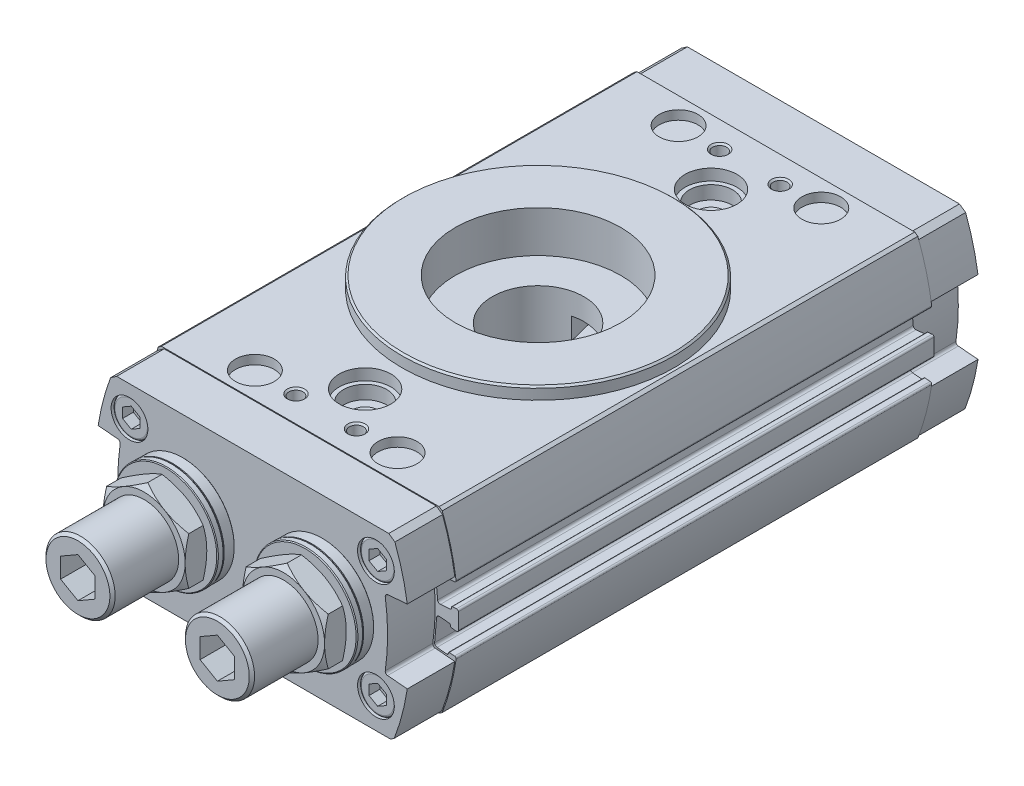
from build123d import *

# Parameters (mm, degrees)
BOSS_EXTRUDE1_DEPTH      = 55
BOSS_EXTRUDE1_DEPTH_BACK = 55
CUT_EXTRUDE1_DEPTH       = 55
CUT_EXTRUDE1_DEPTH_BACK  = 55
CUT_EXTRUDE2_DEPTH       = 55
CUT_EXTRUDE2_DEPTH_BACK  = 55
BOSS_EXTRUDE2_DEPTH      = 11
BOSS_EXTRUDE3_START      = 11
BOSS_EXTRUDE3_DEPTH      = 11
SKETCH16_W               = 4.5
SKETCH16_H               = 2.1
SKETCH17_W               = 4.5
SKETCH17_H               = 2.1
SKETCH18_W               = 4.5
SKETCH18_H               = 2.1
SKETCH19_W               = 4.5
SKETCH19_H               = 2.1
CUT_EXTRUDE3_DEPTH       = 2.5
CUT_EXTRUDE4_DEPTH       = 2.5
CUT_EXTRUDE5_DEPTH       = 2.5
CUT_EXTRUDE6_DEPTH       = 2.5
CUT_EXTRUDE7_DEPTH       = 2.5
CUT_EXTRUDE8_DEPTH       = 2.5
CUT_EXTRUDE9_DEPTH       = 2.5
CUT_EXTRUDE10_DEPTH      = 2.5
BOSS_EXTRUDE4_DEPTH      = 5
BOSS_EXTRUDE5_DEPTH      = 5
CUT_EXTRUDE11_DEPTH      = 6
CUT_EXTRUDE12_DEPTH      = 6
CUT_EXTRUDE13_DEPTH      = 2
CUT_EXTRUDE14_DEPTH      = 2
SKETCH52_W               = 17.125
SKETCH52_H               = 5
CUT_REVOLVE26_ANGLE      = 208


with BuildPart() as part:
    # Sketch1 → Boss-Extrude1 (new, two sides: drawn at the far end of the back side and taken through both)
    with BuildSketch(Plane.XY.offset(-BOSS_EXTRUDE1_DEPTH_BACK)):
        with BuildLine():
            Line((-32.829876508, 0.5), (-32.115802504, 0))
            Line((-32.115802504, 0), (32.115802504, 0))
            Line((32.115802504, 0), (32.829876508, 0.5))
            ThreePointArc((32.829876508, 0.5), (36.6, 20.7), (32.829876508, 40.9))
            Line((32.829876508, 40.9), (32.115802504, 41.4))
            Line((32.115802504, 41.4), (-32.115802504, 41.4))
            Line((-32.115802504, 41.4), (-32.829876508, 40.9))
            ThreePointArc((-32.829876508, 40.9), (-36.6, 20.7), (-32.829876508, 0.5))
        make_face()
    extrude(amount=BOSS_EXTRUDE1_DEPTH + BOSS_EXTRUDE1_DEPTH_BACK)

    # Sketch2 → Cut-Extrude1 (cut, two sides: drawn at the far end of the back side and taken through both)
    with BuildSketch(Plane.XY.offset(-CUT_EXTRUDE1_DEPTH_BACK)):
        with BuildLine():
            Line((31.617877692, 12.954236438), (33.909125497, 12.753778229))
            ThreePointArc((33.909125497, 12.753778229), (34.128108503, 12.822823306), (34.23413063, 13.026489916))
            Line((34.23413063, 13.026489916), (34.247203991, 13.175919121))
            ThreePointArc((34.247203991, 13.175919121), (34.317885409, 13.311696861), (34.463874079, 13.357726912))
            Line((34.463874079, 13.357726912), (35.678340958, 13.251474828))
            ThreePointArc((35.678340958, 13.251474828), (35.956768235, 13.101692833), (36.03947491, 12.796543689))
            Line((36.03947491, 12.796543689), (41.6, 12.796543689))
            Line((41.6, 12.796543689), (41.6, 28.583696395))
            Line((41.6, 28.583696395), (36.042288293, 28.583696395))
            ThreePointArc((36.042288293, 28.583696395), (35.959517197, 28.278632566), (35.681134245, 28.128906398))
            Line((35.681134245, 28.128906398), (34.690910982, 28.042273088))
            ThreePointArc((34.690910982, 28.042273088), (34.544922312, 28.088303139), (34.474240894, 28.224080879))
            Line((34.474240894, 28.224080879), (34.461167533, 28.373510084))
            ThreePointArc((34.461167533, 28.373510084), (34.355145406, 28.577176694), (34.1361624, 28.646221771))
            Line((34.1361624, 28.646221771), (31.844914595, 28.445763562))
            ThreePointArc((31.844914595, 28.445763562), (31.437581375, 28.233719309), (31.299491222, 27.795753298))
            Line((31.299491222, 27.795753298), (31.761416658, 22.515921398))
            ThreePointArc((31.761416658, 22.515921398), (31.973460911, 22.108588178), (32.411426923, 21.970498025))
            Line((32.411426923, 21.970498025), (34.702674728, 22.170956233))
            ThreePointArc((34.702674728, 22.170956233), (34.906341338, 22.27697836), (34.975386415, 22.495961365))
            Line((34.975386415, 22.495961365), (34.962313054, 22.64539057))
            ThreePointArc((34.962313054, 22.64539057), (35.008343105, 22.791379241), (35.144120845, 22.862060658))
            Line((35.144120845, 22.862060658), (36.134344107, 22.948693968))
            ThreePointArc((36.134344107, 22.948693968), (36.434497473, 22.849583169), (36.568984868, 22.563526996))
            ThreePointArc((36.568984868, 22.563526996), (36.599999111, 20.690020595), (36.568317138, 18.816525367))
            ThreePointArc((36.568317138, 18.816525367), (36.433781161, 18.530564406), (36.133681147, 18.431500878))
            Line((36.133681147, 18.431500878), (34.917083941, 18.537939342))
            ThreePointArc((34.917083941, 18.537939342), (34.781306201, 18.608620759), (34.73527615, 18.75460943))
            Line((34.73527615, 18.75460943), (34.748349512, 18.904038635))
            ThreePointArc((34.748349512, 18.904038635), (34.679304435, 19.12302164), (34.475637825, 19.229043767))
            Line((34.475637825, 19.229043767), (32.18439002, 19.429501975))
            ThreePointArc((32.18439002, 19.429501975), (31.746424008, 19.291411822), (31.534379755, 18.884078602))
            Line((31.534379755, 18.884078602), (31.072454319, 13.604246702))
            ThreePointArc((31.072454319, 13.604246702), (31.210544472, 13.166280691), (31.617877692, 12.954236438))
        make_face()
    extrude(amount=CUT_EXTRUDE1_DEPTH + CUT_EXTRUDE1_DEPTH_BACK, mode=Mode.SUBTRACT)

    # Sketch3 → Cut-Extrude2 (cut, two sides: drawn at the far end of the back side and taken through both)
    with BuildSketch(Plane.XY.offset(-CUT_EXTRUDE2_DEPTH_BACK)):
        with BuildLine():
            Line((-41.6, 12.796543689), (-36.03947491, 12.796543689))
            ThreePointArc((-36.03947491, 12.796543689), (-35.956768235, 13.101692833), (-35.678340958, 13.251474828))
            Line((-35.678340958, 13.251474828), (-34.463874079, 13.357726912))
            ThreePointArc((-34.463874079, 13.357726912), (-34.317885409, 13.311696861), (-34.247203991, 13.175919121))
            Line((-34.247203991, 13.175919121), (-34.23413063, 13.026489916))
            ThreePointArc((-34.23413063, 13.026489916), (-34.128108503, 12.822823306), (-33.909125497, 12.753778229))
            Line((-33.909125497, 12.753778229), (-31.617877692, 12.954236438))
            ThreePointArc((-31.617877692, 12.954236438), (-31.210544472, 13.166280691), (-31.072454319, 13.604246702))
            Line((-31.072454319, 13.604246702), (-31.534379755, 18.884078602))
            ThreePointArc((-31.534379755, 18.884078602), (-31.746424008, 19.291411822), (-32.18439002, 19.429501975))
            Line((-32.18439002, 19.429501975), (-34.475637825, 19.229043767))
            ThreePointArc((-34.475637825, 19.229043767), (-34.679304435, 19.12302164), (-34.748349512, 18.904038635))
            Line((-34.748349512, 18.904038635), (-34.73527615, 18.75460943))
            ThreePointArc((-34.73527615, 18.75460943), (-34.781306201, 18.608620759), (-34.917083941, 18.537939342))
            Line((-34.917083941, 18.537939342), (-36.133681147, 18.431500878))
            ThreePointArc((-36.133681147, 18.431500878), (-36.433781161, 18.530564406), (-36.568317138, 18.816525367))
            ThreePointArc((-36.568317138, 18.816525367), (-36.599999111, 20.690020595), (-36.568984868, 22.563526996))
            ThreePointArc((-36.568984868, 22.563526996), (-36.434497473, 22.849583169), (-36.134344107, 22.948693968))
            Line((-36.134344107, 22.948693968), (-35.144120845, 22.862060658))
            ThreePointArc((-35.144120845, 22.862060658), (-35.008343105, 22.791379241), (-34.962313054, 22.64539057))
            Line((-34.962313054, 22.64539057), (-34.975386415, 22.495961365))
            ThreePointArc((-34.975386415, 22.495961365), (-34.906341338, 22.27697836), (-34.702674728, 22.170956233))
            Line((-34.702674728, 22.170956233), (-32.411426923, 21.970498025))
            ThreePointArc((-32.411426923, 21.970498025), (-31.973460911, 22.108588178), (-31.761416658, 22.515921398))
            Line((-31.761416658, 22.515921398), (-31.299491222, 27.795753298))
            ThreePointArc((-31.299491222, 27.795753298), (-31.437581375, 28.233719309), (-31.844914595, 28.445763562))
            Line((-31.844914595, 28.445763562), (-34.1361624, 28.646221771))
            ThreePointArc((-34.1361624, 28.646221771), (-34.355145406, 28.577176694), (-34.461167533, 28.373510084))
            Line((-34.461167533, 28.373510084), (-34.474240894, 28.224080879))
            ThreePointArc((-34.474240894, 28.224080879), (-34.544922312, 28.088303139), (-34.690910982, 28.042273088))
            Line((-34.690910982, 28.042273088), (-35.681134245, 28.128906398))
            ThreePointArc((-35.681134245, 28.128906398), (-35.959517197, 28.278632566), (-36.042288293, 28.583696395))
            Line((-36.042288293, 28.583696395), (-41.6, 28.583696395))
            Line((-41.6, 28.583696395), (-41.6, 12.796543689))
        make_face()
    extrude(amount=CUT_EXTRUDE2_DEPTH + CUT_EXTRUDE2_DEPTH_BACK, mode=Mode.SUBTRACT)

    # Sketch4 → Boss-Extrude2 (add)
    with BuildSketch(Plane.XY.offset(-55)):
        with BuildLine():
            Line((-35.75115175, 29.2), (-31.197015953, 28.801564746))
            ThreePointArc((-31.197015953, 28.801564746), (-30.7784612, 28.575737661), (-30.655737693, 28.116254371))
            ThreePointArc((-30.655737693, 28.116254371), (-31.2, 20.7), (-30.655737693, 13.283745629))
            ThreePointArc((-30.655737693, 13.283745629), (-30.7784612, 12.824262339), (-31.197015953, 12.598435254))
            Line((-31.197015953, 12.598435254), (-35.75115175, 12.2))
            ThreePointArc((-35.75115175, 12.2), (-34.548874719, 6.420666449), (-32.744913793, 0.8))
            Line((-32.744913793, 0.8), (-31.888024989, 0.2))
            Line((-31.888024989, 0.2), (31.888024989, 0.2))
            Line((31.888024989, 0.2), (32.744913793, 0.8))
            ThreePointArc((32.744913793, 0.8), (34.548874719, 6.420666449), (35.75115175, 12.2))
            Line((35.75115175, 12.2), (31.197015953, 12.598435254))
            ThreePointArc((31.197015953, 12.598435254), (30.7784612, 12.824262339), (30.655737693, 13.283745629))
            ThreePointArc((30.655737693, 13.283745629), (31.2, 20.7), (30.655737693, 28.116254371))
            ThreePointArc((30.655737693, 28.116254371), (30.7784612, 28.575737661), (31.197015953, 28.801564746))
            Line((31.197015953, 28.801564746), (35.75115175, 29.2))
            ThreePointArc((35.75115175, 29.2), (34.60299862, 34.772488783), (32.895343216, 40.199716424))
            Line((32.895343216, 40.199716424), (31.466790221, 41.2))
            Line((31.466790221, 41.2), (-31.466790221, 41.2))
            Line((-31.466790221, 41.2), (-32.895343216, 40.199716424))
            ThreePointArc((-32.895343216, 40.199716424), (-34.60299862, 34.772488783), (-35.75115175, 29.2))
        make_face()
    extrude(amount=-BOSS_EXTRUDE2_DEPTH)

    # Sketch5 → Boss-Extrude3 (add)
    with BuildSketch(Plane.XY.offset(55).offset(BOSS_EXTRUDE3_START)):
        with BuildLine():
            Line((-35.75115175, 29.2), (-31.197015953, 28.801564746))
            ThreePointArc((-31.197015953, 28.801564746), (-30.7784612, 28.575737661), (-30.655737693, 28.116254371))
            ThreePointArc((-30.655737693, 28.116254371), (-31.2, 20.7), (-30.655737693, 13.283745629))
            ThreePointArc((-30.655737693, 13.283745629), (-30.7784612, 12.824262339), (-31.197015953, 12.598435254))
            Line((-31.197015953, 12.598435254), (-35.75115175, 12.2))
            ThreePointArc((-35.75115175, 12.2), (-34.548874719, 6.420666449), (-32.744913793, 0.8))
            Line((-32.744913793, 0.8), (-31.888024989, 0.2))
            Line((-31.888024989, 0.2), (31.888024989, 0.2))
            Line((31.888024989, 0.2), (32.744913793, 0.8))
            ThreePointArc((32.744913793, 0.8), (34.548874719, 6.420666449), (35.75115175, 12.2))
            Line((35.75115175, 12.2), (31.197015953, 12.598435254))
            ThreePointArc((31.197015953, 12.598435254), (30.7784612, 12.824262339), (30.655737693, 13.283745629))
            ThreePointArc((30.655737693, 13.283745629), (31.2, 20.7), (30.655737693, 28.116254371))
            ThreePointArc((30.655737693, 28.116254371), (30.7784612, 28.575737661), (31.197015953, 28.801564746))
            Line((31.197015953, 28.801564746), (35.75115175, 29.2))
            ThreePointArc((35.75115175, 29.2), (34.60299862, 34.772488783), (32.895343216, 40.199716424))
            Line((32.895343216, 40.199716424), (31.466790221, 41.2))
            Line((31.466790221, 41.2), (-31.466790221, 41.2))
            Line((-31.466790221, 41.2), (-32.895343216, 40.199716424))
            ThreePointArc((-32.895343216, 40.199716424), (-34.60299862, 34.772488783), (-35.75115175, 29.2))
        make_face()
    extrude(amount=-BOSS_EXTRUDE3_DEPTH)

    # Sketch6 → Cut-Revolve1 (revolve, cut)
    with BuildSketch(Plane(origin=(0, 20.7, 0), x_dir=(1, 0, 0), z_dir=(0, 1, 0))):
        Polygon((10, 66), (12.5, 66), (12.067, 65.567), (12.067, 59), (10, 57.806616994), align=None)
    revolve(axis=Axis((10, 20.7, -57.806616994), (0, 0, -1)), mode=Mode.SUBTRACT)

    # Sketch7 → Cut-Revolve2 (revolve, cut)
    with BuildSketch(Plane(origin=(0, 20.7, 0), x_dir=(1, 0, 0), z_dir=(0, 1, 0))):
        Polygon((-10, 66), (-7.5, 66), (-7.933, 65.567), (-7.933, 59), (-10, 57.806616994), align=None)
    revolve(axis=Axis((-10, 20.7, -57.806616994), (0, 0, -1)), mode=Mode.SUBTRACT)

    # Sketch8 → Revolve1 (revolve)
    with BuildSketch(Plane.XY):
        Polygon((0, 44.2), (31.1, 44.2), (31.5, 43.8), (31.5, 41.4), (0, 41.4), align=None)
    revolve(axis=Axis((0, 41.4, 0), (0, 1, 0)))

    # Sketch9 → Cut-Revolve3 (revolve, cut)
    with BuildSketch(Plane.XY):
        Polygon((0, 44.7), (19.125, 44.7), (19.125, 34.6), (10.6, 34.6), (10.6, 9), (7.5, 9), (7.5, 1.4), (8.5, 1.4), (8.5, 0), (0, 0), align=None)
    revolve(axis=Axis((0, 0, 0), (0, 1, 0)), mode=Mode.SUBTRACT)

    # Sketch10 → Cut-Revolve4 (revolve, cut)
    with BuildSketch(Plane(origin=(0, 0, 0), x_dir=(0, 0, -1), z_dir=(1, 0, 0))):
        Polygon((40, 41.4), (46, 41.4), (46, 38.8), (45, 38.8), (45, 35.7), (43, 35.7), (42.4585, 35.1585), (42.4585, 3.1415), (43, 2.6), (46, 2.6), (46, 0), (40, 0), align=None)
    revolve(axis=Axis((0, 0, -40), (0, 1, 0)), mode=Mode.SUBTRACT)

    # Sketch11 → Cut-Revolve5 (revolve, cut)
    with BuildSketch(Plane(origin=(0, 0, 0), x_dir=(0, 0, -1), z_dir=(1, 0, 0))):
        Polygon((-40, 41.4), (-34, 41.4), (-34, 38.8), (-35, 38.8), (-35, 35.7), (-37, 35.7), (-37.5415, 35.1585), (-37.5415, 3.1415), (-37, 2.6), (-34, 2.6), (-34, 0), (-40, 0), align=None)
    revolve(axis=Axis((0, 0, 40), (0, 1, 0)), mode=Mode.SUBTRACT)

    # Sketch12 → Cut-Revolve6 (revolve, cut)
    with BuildSketch(Plane.XY.offset(49)):
        Polygon((7, 41.4), (9, 41.4), (8.621, 41.021), (8.621, 32.9), (7, 31.964115214), align=None)
    revolve(axis=Axis((7, 31.964115214, 49), (0, 1, 0)), mode=Mode.SUBTRACT)

    # Sketch13 → Cut-Revolve7 (revolve, cut)
    with BuildSketch(Plane.XY.offset(49)):
        Polygon((-7, 41.4), (-5, 41.4), (-5.379, 41.021), (-5.379, 32.9), (-7, 31.964115214), align=None)
    revolve(axis=Axis((-7, 31.964115214, 49), (0, 1, 0)), mode=Mode.SUBTRACT)

    # Sketch14 → Cut-Revolve8 (revolve, cut)
    with BuildSketch(Plane.XY.offset(-49)):
        Polygon((7, 41.4), (9, 41.4), (8.621, 41.021), (8.621, 32.9), (7, 31.964115214), align=None)
    revolve(axis=Axis((7, 31.964115214, -49), (0, 1, 0)), mode=Mode.SUBTRACT)

    # Sketch15 → Cut-Revolve9 (revolve, cut)
    with BuildSketch(Plane.XY.offset(-49)):
        Polygon((-7, 41.4), (-5, 41.4), (-5.379, 41.021), (-5.379, 32.9), (-7, 31.964115214), align=None)
    revolve(axis=Axis((-7, 31.964115214, -49), (0, 1, 0)), mode=Mode.SUBTRACT)

    # Sketch16 → Cut-Revolve10 (revolve, cut)
    with BuildSketch(Plane.XY.offset(49)):
        with Locations((18.75, 40.35)):
            Rectangle(SKETCH16_W, SKETCH16_H)
    revolve(axis=Axis((16.5, 39.3, 49), (0, 1, 0)), mode=Mode.SUBTRACT)

    # Sketch17 → Cut-Revolve11 (revolve, cut)
    with BuildSketch(Plane.XY.offset(49)):
        with Locations((-14.25, 40.35)):
            Rectangle(SKETCH17_W, SKETCH17_H)
    revolve(axis=Axis((-16.5, 39.3, 49), (0, 1, 0)), mode=Mode.SUBTRACT)

    # Sketch18 → Cut-Revolve12 (revolve, cut)
    with BuildSketch(Plane.XY.offset(-49)):
        with Locations((18.75, 40.35)):
            Rectangle(SKETCH18_W, SKETCH18_H)
    revolve(axis=Axis((16.5, 39.3, -49), (0, 1, 0)), mode=Mode.SUBTRACT)

    # Sketch19 → Cut-Revolve13 (revolve, cut)
    with BuildSketch(Plane.XY.offset(-49)):
        with Locations((-14.25, 40.35)):
            Rectangle(SKETCH19_W, SKETCH19_H)
    revolve(axis=Axis((-16.5, 39.3, -49), (0, 1, 0)), mode=Mode.SUBTRACT)

    # Sketch20 → Cut-Revolve14 (revolve, cut)
    with BuildSketch(Plane(origin=(0, 7.2, 0), x_dir=(1, 0, 0), z_dir=(0, 1, 0))):
        with BuildLine():
            Line((28.5, 66), (32.75, 66))
            Line((32.75, 66), (32.75, 65.1))
            ThreePointArc((32.75, 65.1), (32.603553391, 65.453553391), (32.25, 65.6))
            Line((32.25, 65.6), (28.5, 65.6))
            Line((28.5, 65.6), (28.5, 66))
        make_face()
    revolve(axis=Axis((28.5, 7.2, -65.6), (0, 0, -1)), mode=Mode.SUBTRACT)

    # Sketch21 → Cut-Revolve15 (revolve, cut)
    with BuildSketch(Plane(origin=(0, 7.2, 0), x_dir=(1, 0, 0), z_dir=(0, 1, 0))):
        with BuildLine():
            Line((-28.5, 66), (-24.25, 66))
            Line((-24.25, 66), (-24.25, 65.1))
            ThreePointArc((-24.25, 65.1), (-24.396446609, 65.453553391), (-24.75, 65.6))
            Line((-24.75, 65.6), (-28.5, 65.6))
            Line((-28.5, 65.6), (-28.5, 66))
        make_face()
    revolve(axis=Axis((-28.5, 7.2, -65.6), (0, 0, -1)), mode=Mode.SUBTRACT)

    # Sketch22 → Cut-Revolve16 (revolve, cut)
    with BuildSketch(Plane(origin=(0, 7.2, 0), x_dir=(1, 0, 0), z_dir=(0, 1, 0))):
        with BuildLine():
            Line((28.5, -65.6), (32.25, -65.6))
            ThreePointArc((32.25, -65.6), (32.603553391, -65.453553391), (32.75, -65.1))
            Line((32.75, -65.1), (32.75, -66))
            Line((32.75, -66), (28.5, -66))
            Line((28.5, -66), (28.5, -65.6))
        make_face()
    revolve(axis=Axis((28.5, 7.2, 66), (0, 0, -1)), mode=Mode.SUBTRACT)

    # Sketch23 → Cut-Revolve17 (revolve, cut)
    with BuildSketch(Plane(origin=(0, 7.2, 0), x_dir=(1, 0, 0), z_dir=(0, 1, 0))):
        with BuildLine():
            Line((-28.5, -65.6), (-24.75, -65.6))
            ThreePointArc((-24.75, -65.6), (-24.396446609, -65.453553391), (-24.25, -65.1))
            Line((-24.25, -65.1), (-24.25, -66))
            Line((-24.25, -66), (-28.5, -66))
            Line((-28.5, -66), (-28.5, -65.6))
        make_face()
    revolve(axis=Axis((-28.5, 7.2, 66), (0, 0, -1)), mode=Mode.SUBTRACT)

    # Sketch24 → Cut-Revolve18 (revolve, cut)
    with BuildSketch(Plane(origin=(0, 34.2, 0), x_dir=(1, 0, 0), z_dir=(0, 1, 0))):
        with BuildLine():
            Line((28.5, 66), (32.75, 66))
            Line((32.75, 66), (32.75, 65.1))
            ThreePointArc((32.75, 65.1), (32.603553391, 65.453553391), (32.25, 65.6))
            Line((32.25, 65.6), (28.5, 65.6))
            Line((28.5, 65.6), (28.5, 66))
        make_face()
    revolve(axis=Axis((28.5, 34.2, -65.6), (0, 0, -1)), mode=Mode.SUBTRACT)

    # Sketch25 → Cut-Revolve19 (revolve, cut)
    with BuildSketch(Plane(origin=(0, 34.2, 0), x_dir=(1, 0, 0), z_dir=(0, 1, 0))):
        with BuildLine():
            Line((-28.5, 66), (-24.25, 66))
            Line((-24.25, 66), (-24.25, 65.1))
            ThreePointArc((-24.25, 65.1), (-24.396446609, 65.453553391), (-24.75, 65.6))
            Line((-24.75, 65.6), (-28.5, 65.6))
            Line((-28.5, 65.6), (-28.5, 66))
        make_face()
    revolve(axis=Axis((-28.5, 34.2, -65.6), (0, 0, -1)), mode=Mode.SUBTRACT)

    # Sketch26 → Cut-Revolve20 (revolve, cut)
    with BuildSketch(Plane(origin=(0, 34.2, 0), x_dir=(1, 0, 0), z_dir=(0, 1, 0))):
        with BuildLine():
            Line((28.5, -65.6), (32.25, -65.6))
            ThreePointArc((32.25, -65.6), (32.603553391, -65.453553391), (32.75, -65.1))
            Line((32.75, -65.1), (32.75, -66))
            Line((32.75, -66), (28.5, -66))
            Line((28.5, -66), (28.5, -65.6))
        make_face()
    revolve(axis=Axis((28.5, 34.2, 66), (0, 0, -1)), mode=Mode.SUBTRACT)

    # Sketch27 → Cut-Revolve21 (revolve, cut)
    with BuildSketch(Plane(origin=(0, 34.2, 0), x_dir=(1, 0, 0), z_dir=(0, 1, 0))):
        with BuildLine():
            Line((-28.5, -65.6), (-24.75, -65.6))
            ThreePointArc((-24.75, -65.6), (-24.396446609, -65.453553391), (-24.25, -65.1))
            Line((-24.25, -65.1), (-24.25, -66))
            Line((-24.25, -66), (-28.5, -66))
            Line((-28.5, -66), (-28.5, -65.6))
        make_face()
    revolve(axis=Axis((-28.5, 34.2, 66), (0, 0, -1)), mode=Mode.SUBTRACT)

    # Sketch28 → Cut-Extrude3 (cut)
    with BuildSketch(Plane.XY.offset(65.6)):
        Polygon((26.5, 33.045299462), (28.5, 31.890598923), (30.5, 33.045299462), (30.5, 35.354700538), (28.5, 36.509401077), (26.5, 35.354700538), align=None)
    extrude(amount=-CUT_EXTRUDE3_DEPTH, mode=Mode.SUBTRACT)

    # Sketch29 → Cut-Extrude4 (cut)
    with BuildSketch(Plane.XY.offset(65.6)):
        Polygon((-30.5, 33.045299462), (-28.5, 31.890598923), (-26.5, 33.045299462), (-26.5, 35.354700538), (-28.5, 36.509401077), (-30.5, 35.354700538), align=None)
    extrude(amount=-CUT_EXTRUDE4_DEPTH, mode=Mode.SUBTRACT)

    # Sketch30 → Cut-Extrude5 (cut)
    with BuildSketch(Plane.XY.offset(65.6)):
        Polygon((26.5, 6.045299462), (28.5, 4.890598923), (30.5, 6.045299462), (30.5, 8.354700538), (28.5, 9.509401077), (26.5, 8.354700538), align=None)
    extrude(amount=-CUT_EXTRUDE5_DEPTH, mode=Mode.SUBTRACT)

    # Sketch31 → Cut-Extrude6 (cut)
    with BuildSketch(Plane.XY.offset(65.6)):
        Polygon((-30.5, 6.045299462), (-28.5, 4.890598923), (-26.5, 6.045299462), (-26.5, 8.354700538), (-28.5, 9.509401077), (-30.5, 8.354700538), align=None)
    extrude(amount=-CUT_EXTRUDE6_DEPTH, mode=Mode.SUBTRACT)

    # Sketch32 → Cut-Extrude7 (cut)
    with BuildSketch(Plane.XY.offset(-65.6)):
        Polygon((26.5, 33.045299462), (28.5, 31.890598923), (30.5, 33.045299462), (30.5, 35.354700538), (28.5, 36.509401077), (26.5, 35.354700538), align=None)
    extrude(amount=CUT_EXTRUDE7_DEPTH, mode=Mode.SUBTRACT)

    # Sketch33 → Cut-Extrude8 (cut)
    with BuildSketch(Plane.XY.offset(-65.6)):
        Polygon((-30.5, 33.045299462), (-28.5, 31.890598923), (-26.5, 33.045299462), (-26.5, 35.354700538), (-28.5, 36.509401077), (-30.5, 35.354700538), align=None)
    extrude(amount=CUT_EXTRUDE8_DEPTH, mode=Mode.SUBTRACT)

    # Sketch34 → Cut-Extrude9 (cut)
    with BuildSketch(Plane.XY.offset(-65.6)):
        Polygon((26.5, 6.045299462), (28.5, 4.890598923), (30.5, 6.045299462), (30.5, 8.354700538), (28.5, 9.509401077), (26.5, 8.354700538), align=None)
    extrude(amount=CUT_EXTRUDE9_DEPTH, mode=Mode.SUBTRACT)

    # Sketch35 → Cut-Extrude10 (cut)
    with BuildSketch(Plane.XY.offset(-65.6)):
        Polygon((-30.5, 6.045299462), (-28.5, 4.890598923), (-26.5, 6.045299462), (-26.5, 8.354700538), (-28.5, 9.509401077), (-30.5, 8.354700538), align=None)
    extrude(amount=CUT_EXTRUDE10_DEPTH, mode=Mode.SUBTRACT)

    # Sketch36 → Revolve2 (revolve)
    with BuildSketch(Plane(origin=(0, 20.7, 0), x_dir=(1, 0, 0), z_dir=(0, 1, 0))):
        Polygon((16.125, -66), (27.975, -66), (28.075, -66.1), (28.075, -68.4), (27.975, -68.5), (16.125, -68.5), align=None)
    revolve(axis=Axis((16.125, 20.7, 68.5), (0, 0, -1)))

    # Sketch37 → Revolve3 (revolve)
    with BuildSketch(Plane(origin=(0, 20.7, 0), x_dir=(1, 0, 0), z_dir=(0, 1, 0))):
        Polygon((-16.125, -66), (-4.275, -66), (-4.175, -66.1), (-4.175, -68.4), (-4.275, -68.5), (-16.125, -68.5), align=None)
    revolve(axis=Axis((-16.125, 20.7, 68.5), (0, 0, -1)))

    # Sketch38 → Revolve4 (revolve)
    with BuildSketch(Plane(origin=(0, 20.7, 0), x_dir=(1, 0, 0), z_dir=(0, 1, 0))):
        Polygon((16.125, -68.5), (27.925, -68.5), (28.125, -68.7), (28.125, -69.8), (27.925, -70), (16.125, -70), align=None)
    revolve(axis=Axis((16.125, 20.7, 70), (0, 0, -1)))

    # Sketch39 → Revolve5 (revolve)
    with BuildSketch(Plane(origin=(0, 20.7, 0), x_dir=(1, 0, 0), z_dir=(0, 1, 0))):
        Polygon((-16.125, -68.5), (-4.337132034, -68.5), (-4.125, -68.712132034), (-4.125, -69.823223305), (-4.301776695, -70), (-16.125, -70), align=None)
    revolve(axis=Axis((-16.125, 20.7, 70), (0, 0, -1)))

    # Sketch40 → Boss-Extrude4 (add)
    with BuildSketch(Plane.XY.offset(70)):
        Polygon((6.625, 15.215172443), (16.125, 9.730344885), (25.625, 15.215172443), (25.625, 26.184827557), (16.125, 31.669655115), (6.625, 26.184827557), align=None)
    extrude(amount=BOSS_EXTRUDE4_DEPTH)

    # Sketch41 → Cut-Revolve22 (revolve, cut)
    with BuildSketch(Plane(origin=(0, 20.7, 0), x_dir=(1, 0, 0), z_dir=(0, 1, 0))):
        Polygon((25.625, -70), (28.075, -71.41450816), (28.075, -73.58549184), (25.625, -75), (29.075, -75), (29.075, -70), align=None)
    revolve(axis=Axis((16.125, 20.7, 75), (0, 0, -1)), mode=Mode.SUBTRACT)

    # Sketch42 → Boss-Extrude5 (add)
    with BuildSketch(Plane.XY.offset(70)):
        Polygon((-25.625, 15.215172443), (-16.125, 9.730344885), (-6.625, 15.215172443), (-6.625, 26.184827557), (-16.125, 31.669655115), (-25.625, 26.184827557), align=None)
    extrude(amount=BOSS_EXTRUDE5_DEPTH)

    # Sketch43 → Cut-Revolve23 (revolve, cut)
    with BuildSketch(Plane(origin=(0, 20.7, 0), x_dir=(1, 0, 0), z_dir=(0, 1, 0))):
        Polygon((-6.625, -75), (-3.175, -75), (-3.175, -70), (-6.625, -70), (-4.175, -71.41450816), (-4.175, -73.58549184), align=None)
    revolve(axis=Axis((-16.125, 20.7, 75), (0, 0, -1)), mode=Mode.SUBTRACT)

    # Sketch44 → Revolve6 (revolve)
    with BuildSketch(Plane(origin=(0, 20.7, 0), x_dir=(1, 0, 0), z_dir=(0, 1, 0))):
        Polygon((16.125, -75), (24.125, -75), (24.125, -89.6865), (23.5115, -90.3), (16.125, -90.3), align=None)
    revolve(axis=Axis((16.125, 20.7, 90.3), (0, 0, -1)))

    # Sketch45 → Revolve7 (revolve)
    with BuildSketch(Plane(origin=(0, 20.7, 0), x_dir=(1, 0, 0), z_dir=(0, 1, 0))):
        Polygon((-16.125, -75), (-8.125, -75), (-8.125, -89.6865), (-8.7385, -90.3), (-16.125, -90.3), align=None)
    revolve(axis=Axis((-16.125, 20.7, 90.3), (0, 0, -1)))

    # Sketch46 → Cut-Extrude11 (cut)
    with BuildSketch(Plane.XY.offset(90.3)):
        Polygon((12.125, 18.390598923), (16.125, 16.081197846), (20.125, 18.390598923), (20.125, 23.009401077), (16.125, 25.318802154), (12.125, 23.009401077), align=None)
    extrude(amount=-CUT_EXTRUDE11_DEPTH, mode=Mode.SUBTRACT)

    # Sketch47 → Cut-Extrude12 (cut)
    with BuildSketch(Plane.XY.offset(90.3)):
        Polygon((-20.125, 18.390598923), (-16.125, 16.081197846), (-12.125, 18.390598923), (-12.125, 23.009401077), (-16.125, 25.318802154), (-20.125, 23.009401077), align=None)
    extrude(amount=-CUT_EXTRUDE12_DEPTH, mode=Mode.SUBTRACT)

    # Sketch48 → Cut-Revolve24 (revolve, cut)
    with BuildSketch(Plane(origin=(0, 0, 0), x_dir=(0, 0, -1), z_dir=(1, 0, 0))):
        with BuildLine():
            Line((27.5, 0.4), (30.5, 0.4))
            ThreePointArc((30.5, 0.4), (30.853553391, 0.546446609), (31, 0.9))
            Line((31, 0.9), (31, 4.4))
            Line((31, 4.4), (31.5, 4.4))
            Line((31.5, 4.4), (31.5, 2.1))
            Line((31.5, 2.1), (32, 2.1))
            Line((32, 2.1), (32, 0))
            Line((32, 0), (27.5, 0))
            Line((27.5, 0), (27.5, 0.4))
        make_face()
    revolve(axis=Axis((0, 0, -27.5), (0, 1, 0)), mode=Mode.SUBTRACT)

    # Sketch49 → Cut-Revolve25 (revolve, cut)
    with BuildSketch(Plane(origin=(0, 0, 0), x_dir=(0, 0, -1), z_dir=(1, 0, 0))):
        with BuildLine():
            Line((-27.5, 0.4), (-24.5, 0.4))
            ThreePointArc((-24.5, 0.4), (-24.146446609, 0.546446609), (-24, 0.9))
            Line((-24, 0.9), (-24, 4.4))
            Line((-24, 4.4), (-23.5, 4.4))
            Line((-23.5, 4.4), (-23.5, 2.1))
            Line((-23.5, 2.1), (-23, 2.1))
            Line((-23, 2.1), (-23, 0))
            Line((-23, 0), (-27.5, 0))
            Line((-27.5, 0), (-27.5, 0.4))
        make_face()
    revolve(axis=Axis((0, 0, 27.5), (0, 1, 0)), mode=Mode.SUBTRACT)

    # Sketch50 → Cut-Extrude13 (cut)
    with BuildSketch(Plane(origin=(0, 0.4, 0), x_dir=(1, 0, 0), z_dir=(0, 1, 0))):
        Polygon((-1.5, 26.633974596), (0, 25.767949192), (1.5, 26.633974596), (1.5, 28.366025404), (0, 29.232050808), (-1.5, 28.366025404), align=None)
    extrude(amount=CUT_EXTRUDE13_DEPTH, mode=Mode.SUBTRACT)

    # Sketch51 → Cut-Extrude14 (cut)
    with BuildSketch(Plane(origin=(0, 0.4, 0), x_dir=(1, 0, 0), z_dir=(0, 1, 0))):
        Polygon((-1.5, -28.366025404), (0, -29.232050808), (1.5, -28.366025404), (1.5, -26.633974596), (0, -25.767949192), (-1.5, -26.633974596), align=None)
    extrude(amount=CUT_EXTRUDE14_DEPTH, mode=Mode.SUBTRACT)

    # Sketch52 → Cut-Revolve26 (revolve, cut)
    with BuildSketch(Plane(origin=(0, 0, 0), x_dir=(-0.241921895599669, 0, -0.9702957262759961), z_dir=(0.9702957262759961, 0, -0.241921895599669))):
        with Locations((8.5625, 27.1)):
            Rectangle(SKETCH52_W, SKETCH52_H)
    revolve(axis=Axis((0, 24.6, 0), (0, -1, 0)), revolution_arc=CUT_REVOLVE26_ANGLE, mode=Mode.SUBTRACT)


solid = part.part
